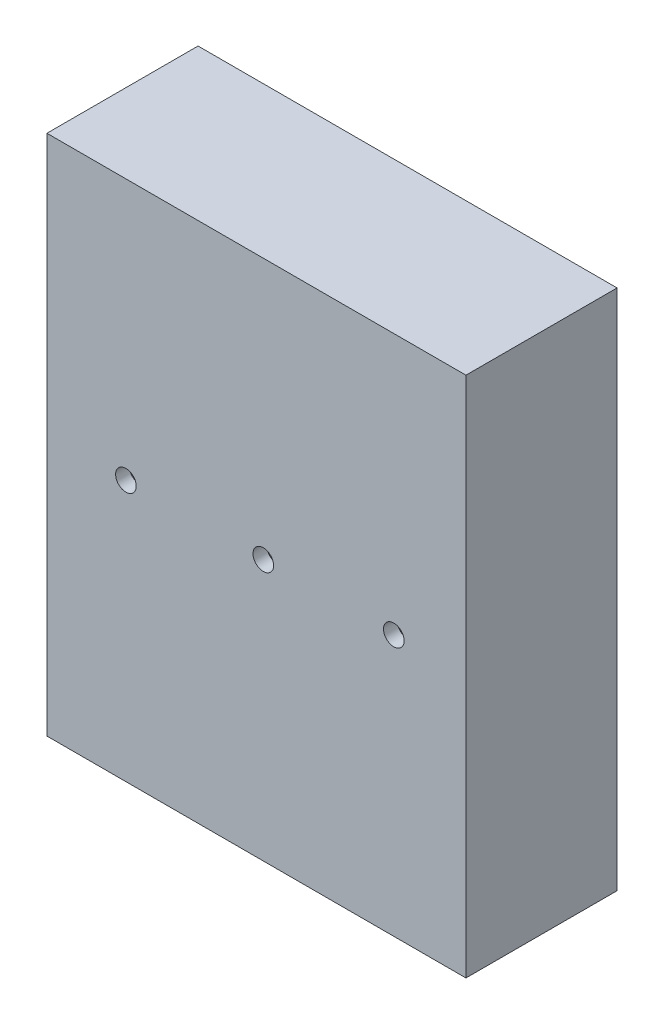
from build123d import *

# Parameters (mm, degrees)
SKETCH1_W               = 81
SKETCH1_H               = 76
SKETCH1_W_2             = 17
SKETCH1_H_2             = 70
SKETCH1_W_3             = 15
BOSS_EXTRUDE2_DEPTH     = 20
SKETCH3_W               = 81
SKETCH3_H               = 76
BOSS_EXTRUDE3_DEPTH     = 2
CUT_EXTRUDE2_DEPTH      = 2
SKETCH5_W               = 17
SKETCH5_H               = 70
SKETCH5_R               = 1.5
CUT_EXTRUDE3_DEPTH      = 21
CUT_EXTRUDE3_DEPTH_BACK = 3


with BuildPart() as part:
    # Sketch1 → Boss-Extrude2 (new body)
    with BuildSketch(Plane.XY):
        with Locations((40.5, -38)):
            Rectangle(SKETCH1_W, SKETCH1_H)
        with Locations((31.5, -38)):
            Rectangle(SKETCH1_W_2, SKETCH1_H_2, mode=Mode.SUBTRACT)
        with Locations((11.5, -38)):
            Rectangle(SKETCH1_W_2, SKETCH1_H_2, mode=Mode.SUBTRACT)
        with Locations((50.5, -38)):
            Rectangle(SKETCH1_W_3, SKETCH1_H_2, mode=Mode.SUBTRACT)
        with Locations((69.5, -38)):
            Rectangle(SKETCH1_W_2, SKETCH1_H_2, mode=Mode.SUBTRACT)
    extrude(amount=BOSS_EXTRUDE2_DEPTH)

    # Sketch3 → Boss-Extrude3 (add)
    with BuildSketch(Plane.XY.offset(20)):
        with Locations((40.5, -38)):
            Rectangle(SKETCH3_W, SKETCH3_H)
    extrude(amount=BOSS_EXTRUDE3_DEPTH)

    # Sketch4 → Cut-Extrude2 (cut)
    with BuildSketch(Plane(origin=(0, 0, 20), x_dir=(-1, 0, 0), z_dir=(0, 0, -1))):
        with BuildLine():
            ThreePointArc((-13, -38), (-11.5, -39.5), (-10, -38))
            Line((-10, -38), (-13, -38))
        make_face()
        with BuildLine():
            Line((-13, -38), (-10, -38))
            ThreePointArc((-10, -38), (-11.5, -36.5), (-13, -38))
        make_face()
        with BuildLine():
            ThreePointArc((-33, -38), (-31.5, -39.5), (-30, -38))
            Line((-30, -38), (-33, -38))
        make_face()
        with BuildLine():
            Line((-33, -38), (-30, -38))
            ThreePointArc((-30, -38), (-31.5, -36.5), (-33, -38))
        make_face()
        with BuildLine():
            ThreePointArc((-52, -38), (-50.5, -39.5), (-49, -38))
            Line((-49, -38), (-52, -38))
        make_face()
        with BuildLine():
            Line((-52, -38), (-49, -38))
            ThreePointArc((-49, -38), (-50.5, -36.5), (-52, -38))
        make_face()
        with BuildLine():
            ThreePointArc((-71, -38), (-69.5, -39.5), (-68, -38))
            Line((-68, -38), (-71, -38))
        make_face()
        with BuildLine():
            Line((-71, -38), (-68, -38))
            ThreePointArc((-68, -38), (-69.5, -36.5), (-71, -38))
        make_face()
    extrude(amount=-CUT_EXTRUDE2_DEPTH, mode=Mode.SUBTRACT)

    # Sketch5 → Cut-Extrude3 (cut, two sides)
    with BuildSketch(Plane(origin=(0, 0, 20), x_dir=(-1, 0, 0), z_dir=(0, 0, -1))) as cut_extrude3_sk:
        Polygon((-61, 3.586024283), (-61, -3), (-78, -3), (-78, -73), (-61, -73), (-61, -79.125259563), (-89.801346659, -78.428276056), (-91.298539163, 3.586024283), align=None)
        with Locations((-69.5, -38)):
            Rectangle(SKETCH5_W, SKETCH5_H)
        with Locations((-69.5, -38)):
            Circle(SKETCH5_R, mode=Mode.SUBTRACT)
    extrude(amount=CUT_EXTRUDE3_DEPTH, mode=Mode.SUBTRACT)
    extrude(cut_extrude3_sk.sketch, amount=-CUT_EXTRUDE3_DEPTH_BACK, mode=Mode.SUBTRACT)


solid = part.part
